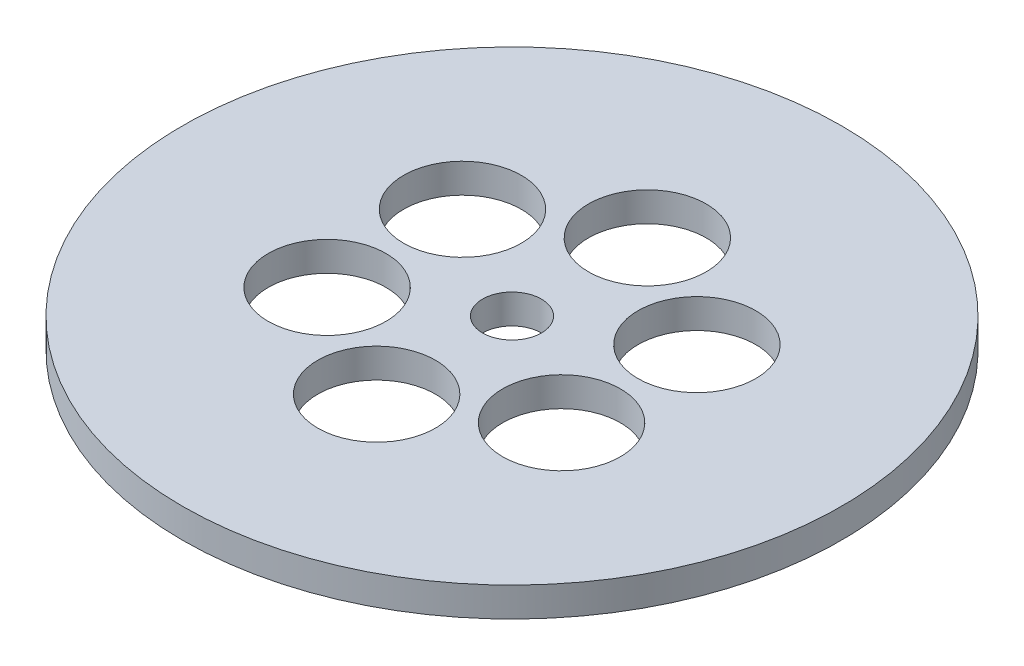
from build123d import *

# Parameters (mm, degrees)
SKETCH1_R           = 71.12
SKETCH1_R_2         = 12.704134002
SKETCH1_R_3         = 6.35
BOSS_EXTRUDE1_DEPTH = 3.175


with BuildPart() as part:
    # Sketch1 → Boss-Extrude1 (new body, symmetric)
    with BuildSketch(Plane(origin=(0, 0, 0), x_dir=(1, 0, 0), z_dir=(0, 1, 0))):
        Circle(SKETCH1_R)
        with Locations((-25.296602045, 14.605)):
            Circle(SKETCH1_R_2, mode=Mode.SUBTRACT)
        with Locations((-25.296602045, -14.605)):
            Circle(SKETCH1_R_2, mode=Mode.SUBTRACT)
        with Locations((0, -29.21)):
            Circle(SKETCH1_R_2, mode=Mode.SUBTRACT)
        with Locations((25.296602045, -14.605)):
            Circle(SKETCH1_R_2, mode=Mode.SUBTRACT)
        with Locations((25.296602045, 14.605)):
            Circle(SKETCH1_R_2, mode=Mode.SUBTRACT)
        with Locations((0, 29.21)):
            Circle(SKETCH1_R_2, mode=Mode.SUBTRACT)
        Circle(SKETCH1_R_3, mode=Mode.SUBTRACT)
    extrude(amount=BOSS_EXTRUDE1_DEPTH, both=True)


solid = part.part
